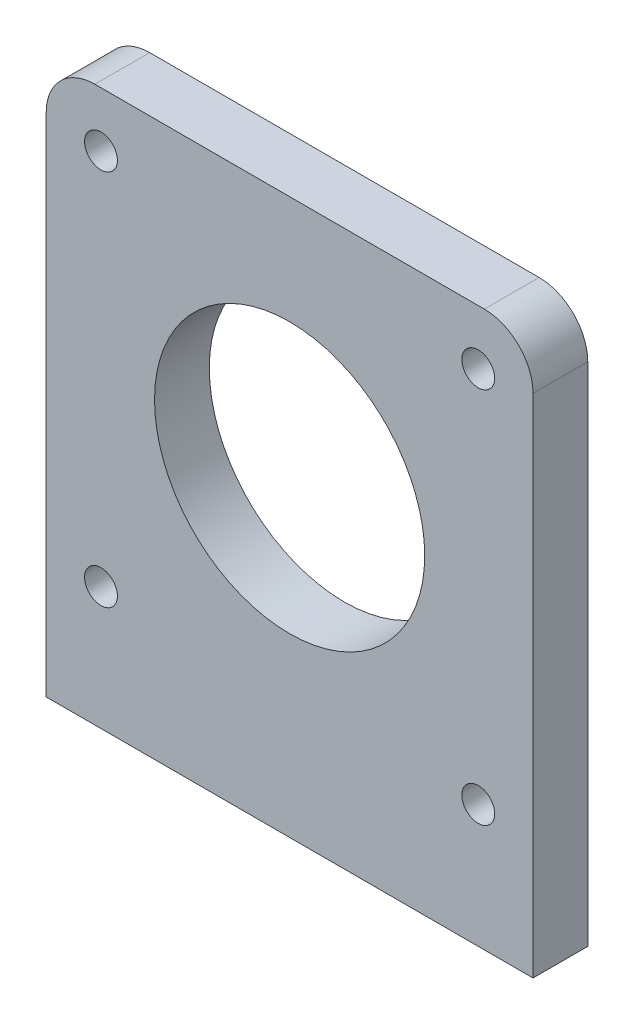
from build123d import *

# Parameters (mm, degrees)
SKETCH1_W           = 40
SKETCH1_H           = 45.6
SKETCH1_R           = 1.35
SKETCH1_R_2         = 11.1
BOSS_EXTRUDE1_DEPTH = 4.5
FILLET1_R           = 4


with BuildPart() as part:
    # Sketch1 → Boss-Extrude1 (new body)
    with BuildSketch(Plane.XY):
        with Locations((0, -2.8)):
            Rectangle(SKETCH1_W, SKETCH1_H)
        with Locations((-15.5, -15.5)):
            Circle(SKETCH1_R, mode=Mode.SUBTRACT)
        with Locations((15.5, -15.5)):
            Circle(SKETCH1_R, mode=Mode.SUBTRACT)
        Circle(SKETCH1_R_2, mode=Mode.SUBTRACT)
        with Locations((-15.5, 15.5)):
            Circle(SKETCH1_R, mode=Mode.SUBTRACT)
        with Locations((15.5, 15.5)):
            Circle(SKETCH1_R, mode=Mode.SUBTRACT)
    extrude(amount=BOSS_EXTRUDE1_DEPTH)

    # Fillet1
    fillet1_edges = [part.edges().sort_by_distance(p)[0] for p in [
        (20, 20, 2.25),
        (-20, 20, 2.25),
    ]]
    fillet(fillet1_edges, radius=FILLET1_R)


solid = part.part
